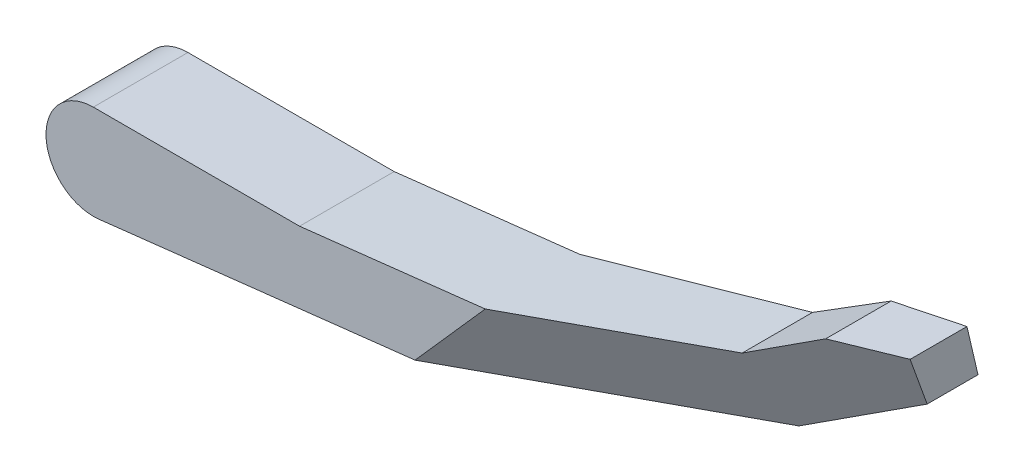
from build123d import *

# Parameters (mm, degrees)
EXTRUDE_START       = -3
EXTRUDE_1_DEPTH     = 8
EXTRUDE_2_DEPTH     = 8
CUT_EXTRUDE_1_DEPTH = 24.482669171


with BuildPart() as part:
    # 草图2 → 凸台-拉伸1 (new body)
    with BuildSketch(Plane.XY.offset(EXTRUDE_START)):
        with BuildLine():
            Line((0.452812855, -3.974287423), (50.958977377, 1.780163155))
            Line((50.958977377, 1.780163155), (60, 7))
            Line((60, 7), (60, 11))
            Line((60, 11), (54.92820323, 11))
            Line((54.92820323, 11), (49.039778636, 7.600316475))
            Line((49.039778636, 7.600316475), (17.440206483, 4))
            Line((17.440206483, 4), (0, 4))
            ThreePointArc((0, 4), (-3.993566682, -0.22677115), (0.452812855, -3.974287423))
        make_face()
    extrude(amount=-EXTRUDE_1_DEPTH)

    # 草图3 → 凸台-拉伸2 (add)
    with BuildSketch(Plane(origin=(0, 0, -11), x_dir=(-1, 0, 0), z_dir=(0, 0, -1))):
        Polygon((-27.201059955, -0.926709618), (-33.142680696, 5.789070951), (-49.039778636, 7.600316475), (-54.92820323, 11), (-60, 11), (-60, 7), (-50.958977377, 1.780163155), align=None)
    extrude(amount=EXTRUDE_2_DEPTH)

    # 草图4 → 切除-拉伸1 (cut, through all, along a direction that is not the sketch's normal)
    with BuildSketch(Plane(origin=(0.452812855, -3.974287423, 0), x_dir=(0.993571856, 0.113203214, 0), z_dir=(0.113203214, -0.993571856, 0))):
        Polygon((26.921301109, -11), (26.921301109, -19), (60.859546692, -19), align=None)
        Polygon((26.921301109, -3), (60.859546692, -15.352511196), (60.859546692, -3), align=None)
    extrude(amount=-CUT_EXTRUDE_1_DEPTH, dir=(-0.662620048, -0.748955721, 0), mode=Mode.SUBTRACT)


solid = part.part
